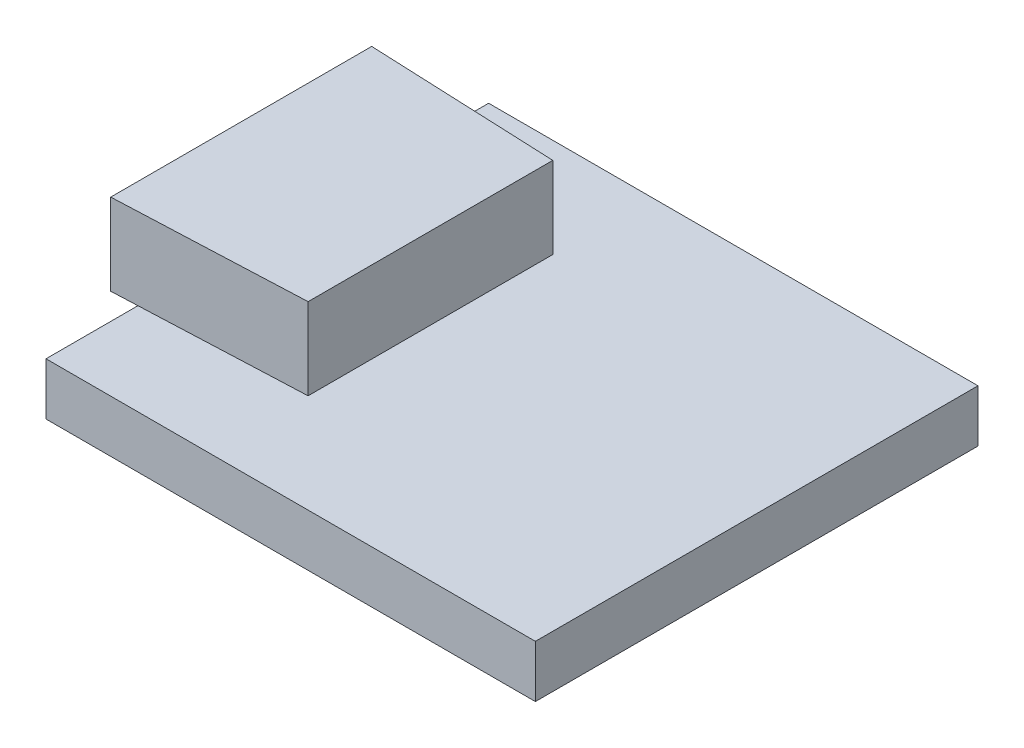
from build123d import *

# Parameters (mm, degrees)
SKETCH_1_W      = 15
SKETCH_1_H      = 13.566666666
EXTRUDE_1_DEPTH = 1.6
EXTRUDE_2_DEPTH = 2.5


with BuildPart() as part:
    # 草图1 → 凸台-拉伸1 (new body)
    with BuildSketch(Plane(origin=(0, 0, 0), x_dir=(1, 0, 0), z_dir=(0, 1, 0))):
        Rectangle(SKETCH_1_W, SKETCH_1_H)
    extrude(amount=EXTRUDE_1_DEPTH)

    # 草图2 → 凸台-拉伸2 (add)
    with BuildSketch(Plane(origin=(0, 1.6, 0), x_dir=(1, 0, 0), z_dir=(0, 1, 0))):
        Polygon((-8.3, -4), (-8.3, 4), (-2.5, 3.75), (-2.5, -3.75), align=None)
    extrude(amount=EXTRUDE_2_DEPTH)


solid = part.part
